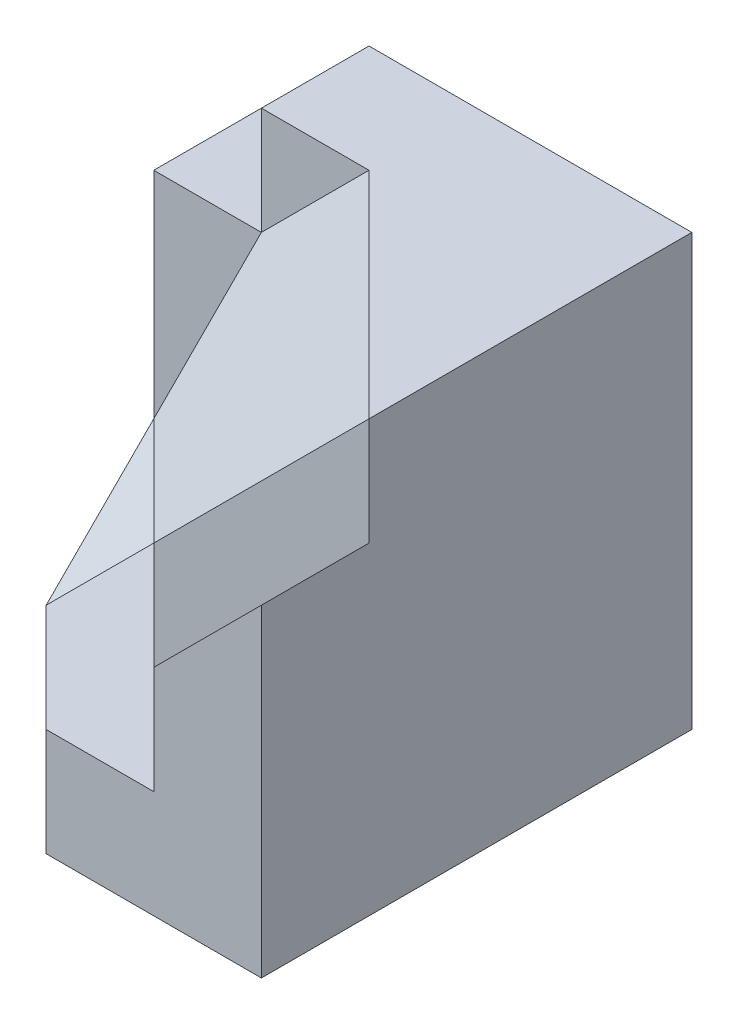
from build123d import *

# Parameters (mm, degrees)
BOSS_EXTRUDE2_DEPTH = 20
BOSS_EXTRUDE4_DEPTH = 5
BOSS_EXTRUDE6_DEPTH = 20
CUT_EXTRUDE1_DEPTH  = 20
SKETCH5_W           = 5
SKETCH5_H           = 15
BOSS_EXTRUDE7_DEPTH = 5
CUT_EXTRUDE2_DEPTH  = 5
BOSS_EXTRUDE8_DEPTH = 5


with BuildPart() as part:
    # Sketch2 → Boss-Extrude2 (new body)
    with BuildSketch(Plane(origin=(0, 0, 0), x_dir=(1, 0, 0), z_dir=(0, 1, 0))):
        Polygon((-15, 0), (0, 0), (0, -15), (-10, -5), (-15, -5), align=None)
    extrude(amount=BOSS_EXTRUDE2_DEPTH)

    # Sketch3 → Boss-Extrude4 (add)
    with BuildSketch(Plane.ZY.offset(15)):
        Polygon((5, 15), (5, 5), (10, 0), (0, 0), (0, 15), align=None)
    extrude(amount=BOSS_EXTRUDE4_DEPTH)

    # Sketch4 → Boss-Extrude6 (add)
    with BuildSketch(Plane(origin=(0, 0, 0), x_dir=(-1, 0, 0), z_dir=(0, -1, 0))):
        Polygon((10, -15), (15, -10), (15, -5), (10, -5), (0, -15), align=None)
    extrude(amount=-BOSS_EXTRUDE6_DEPTH)

    # 3DSketch2 → Cut-Extrude1 (cut, along a direction that is not the sketch's normal)
    with BuildSketch(Plane(origin=(-10, 20, 5), x_dir=(0.7071067811865476, 0, 0.7071067811865475), z_dir=(0.5773502691896257, -0.577350269189626, -0.5773502691896258))):
        Polygon((0, 0), (14.142135624, 0), (7.071067812, 12.247448714), (0, 12.247448714), (-3.535533906, 6.123724357), align=None)
    extrude(amount=-CUT_EXTRUDE1_DEPTH, dir=(0, -1, 0), mode=Mode.SUBTRACT)

    # Sketch5 → Boss-Extrude7 (add)
    with BuildSketch(Plane.XY.offset(15)):
        with Locations((-2.5, 7.5)):
            Rectangle(SKETCH5_W, SKETCH5_H)
    extrude(amount=BOSS_EXTRUDE7_DEPTH)

    # Sketch6 → Cut-Extrude2 (cut)
    with BuildSketch(Plane.XY.offset(20)):
        Polygon((0, 15), (-5, 15), (-5, 10), align=None)
    extrude(amount=-CUT_EXTRUDE2_DEPTH, mode=Mode.SUBTRACT)

    # Sketch7 → Boss-Extrude8 (add)
    with BuildSketch(Plane(origin=(0, 0, 0), x_dir=(-1, 0, 0), z_dir=(0, -1, 0))):
        Polygon((15, -10), (10, -15), (5, -15), (5, -20), (10, -20), (15, -15), align=None)
    extrude(amount=-BOSS_EXTRUDE8_DEPTH)


solid = part.part
